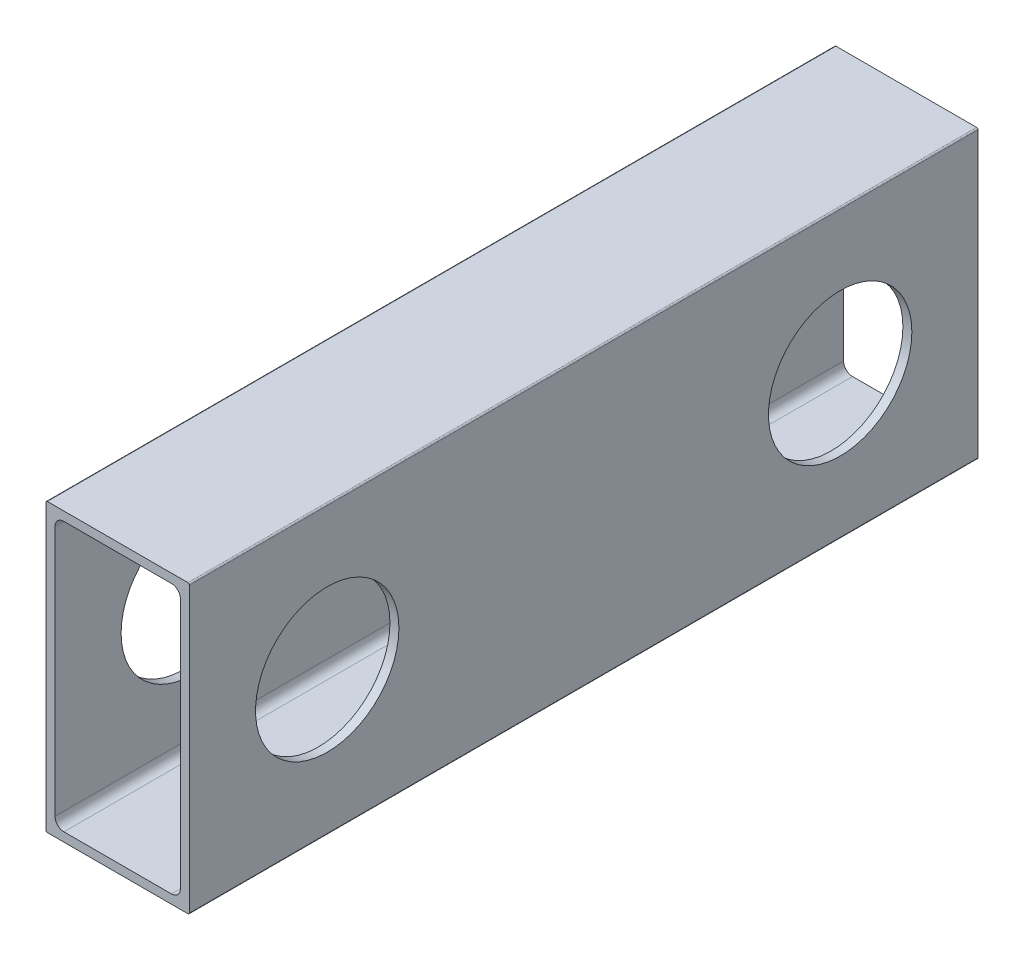
from build123d import *

# Parameters (mm, degrees)
BOSS_EXTRUDE1_DEPTH = 139.7
SKETCH2_R           = 12.7
CUT_EXTRUDE2_DEPTH  = 26.4


with BuildPart() as part:
    # Sketch1 → Boss-Extrude1 (new body)
    with BuildSketch(Plane(origin=(0, 0, 0), x_dir=(-1, 0, 0), z_dir=(0, 0, -1))):
        with BuildLine():
            Line((-12.7, 25.146), (-12.7, -25.146))
            ThreePointArc((-12.7, -25.146), (-12.625605122, -25.325605122), (-12.446, -25.4))
            Line((-12.446, -25.4), (12.446, -25.4))
            ThreePointArc((12.446, -25.4), (12.625605122, -25.325605122), (12.7, -25.146))
            Line((12.7, -25.146), (12.7, 25.146))
            ThreePointArc((12.7, 25.146), (12.625605122, 25.325605122), (12.446, 25.4))
            Line((12.446, 25.4), (-12.446, 25.4))
            ThreePointArc((-12.446, 25.4), (-12.625605122, 25.325605122), (-12.7, 25.146))
        make_face()
        with BuildLine():
            Line((-11.1125, -22.225), (-11.1125, 22.225))
            ThreePointArc((-11.1125, 22.225), (-10.647532015, 23.347532015), (-9.525, 23.8125))
            Line((-9.525, 23.8125), (9.525, 23.8125))
            ThreePointArc((9.525, 23.8125), (10.647532015, 23.347532015), (11.1125, 22.225))
            Line((11.1125, 22.225), (11.1125, -22.225))
            ThreePointArc((11.1125, -22.225), (10.647532015, -23.347532015), (9.525, -23.8125))
            Line((9.525, -23.8125), (-9.525, -23.8125))
            ThreePointArc((-9.525, -23.8125), (-10.647532015, -23.347532015), (-11.1125, -22.225))
        make_face(mode=Mode.SUBTRACT)
    extrude(amount=-BOSS_EXTRUDE1_DEPTH)

    # Sketch2 → Cut-Extrude2 (cut, through all)
    with BuildSketch(Plane(origin=(12.7, 0, 0), x_dir=(0, 0, -1), z_dir=(1, 0, 0))):
        with Locations((-115.282472, 0)):
            Circle(SKETCH2_R)
        with Locations((-24.417528, 0)):
            Circle(SKETCH2_R)
    extrude(amount=-CUT_EXTRUDE2_DEPTH, mode=Mode.SUBTRACT)


solid = part.part
